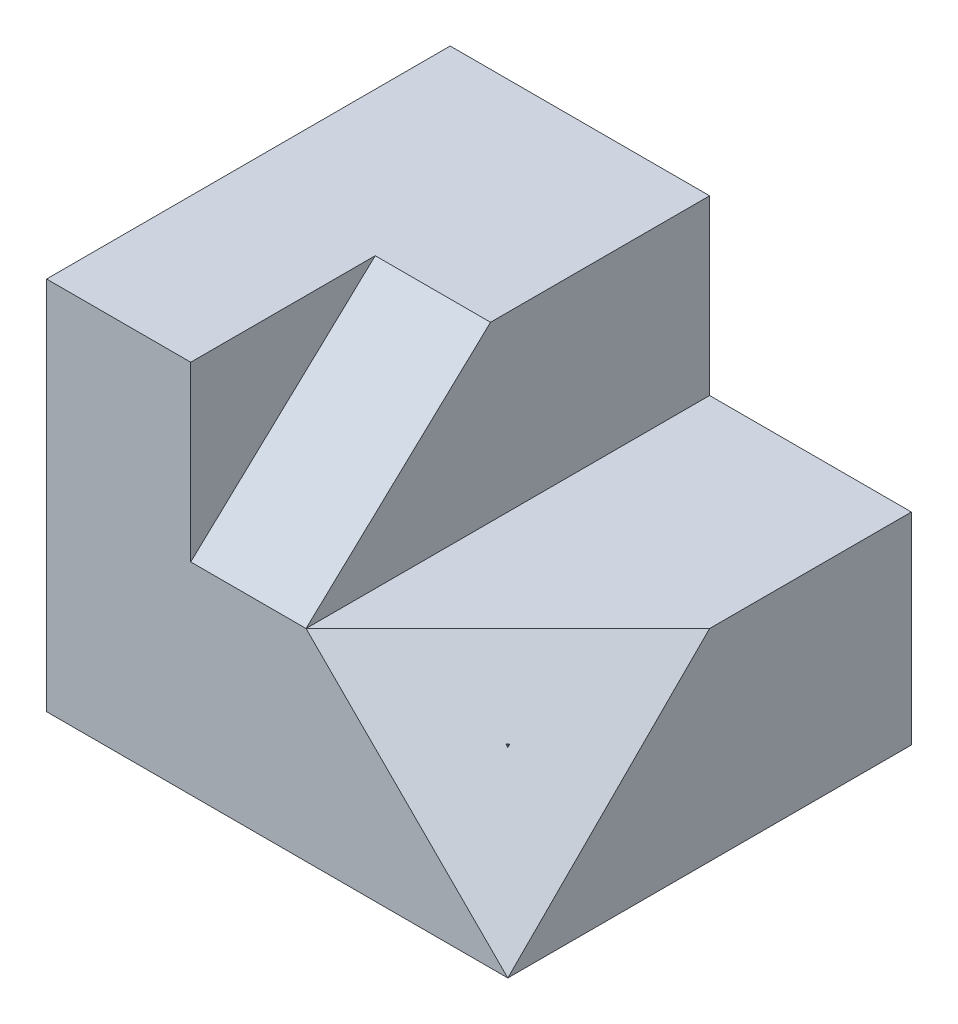
from build123d import *

# Parameters (mm, degrees)
SKETCH2_W           = 80
SKETCH2_H           = 70
BOSS_EXTRUDE1_DEPTH = 65
SKETCH3_W           = 70
SKETCH3_H           = 30
CUT_EXTRUDE1_DEPTH  = 35
BOSS_EXTRUDE2_DEPTH = 20
CUT_EXTRUDE2_DEPTH  = 20
CUT_EXTRUDE3_DEPTH  = 20


with BuildPart() as part:
    # Sketch2 → Boss-Extrude1 (new body)
    with BuildSketch(Plane(origin=(0, 0, 0), x_dir=(1, 0, 0), z_dir=(0, 1, 0))):
        Rectangle(SKETCH2_W, SKETCH2_H)
    extrude(amount=BOSS_EXTRUDE1_DEPTH)

    # Sketch3 → Cut-Extrude1 (cut)
    with BuildSketch(Plane(origin=(40, 0, 0), x_dir=(0, 0, -1), z_dir=(1, 0, 0))):
        with Locations((0, 50)):
            Rectangle(SKETCH3_W, SKETCH3_H)
    extrude(amount=-CUT_EXTRUDE1_DEPTH, mode=Mode.SUBTRACT)

    # Sketch4 → Boss-Extrude2 (add)
    with BuildSketch(Plane(origin=(5, 0, 0), x_dir=(0, 0, -1), z_dir=(1, 0, 0))):
        Polygon((-35, 35), (-3, 65), (-35, 65), align=None)
    extrude(amount=-BOSS_EXTRUDE2_DEPTH)

    # Sketch5 → Cut-Extrude2 (cut)
    with BuildSketch(Plane(origin=(5, 0, 0), x_dir=(0, 0, -1), z_dir=(1, 0, 0))):
        Polygon((-35, 35), (-3, 65), (-35, 65), align=None)
    extrude(amount=-CUT_EXTRUDE2_DEPTH, mode=Mode.SUBTRACT)

    # Sketch6 → Cut-Extrude3 (cut)
    with BuildSketch(Plane(origin=(25, 25, 25), x_dir=(-0.816496581, 0.40824829, 0.40824829), z_dir=(-0.577350269, -0.577350269, -0.577350269))):
        Polygon((-18.371173071, -24.748737342), (-18.371173071, 24.748737342), (24.494897428, 0), align=None)
    extrude(amount=-CUT_EXTRUDE3_DEPTH, mode=Mode.SUBTRACT)


solid = part.part
